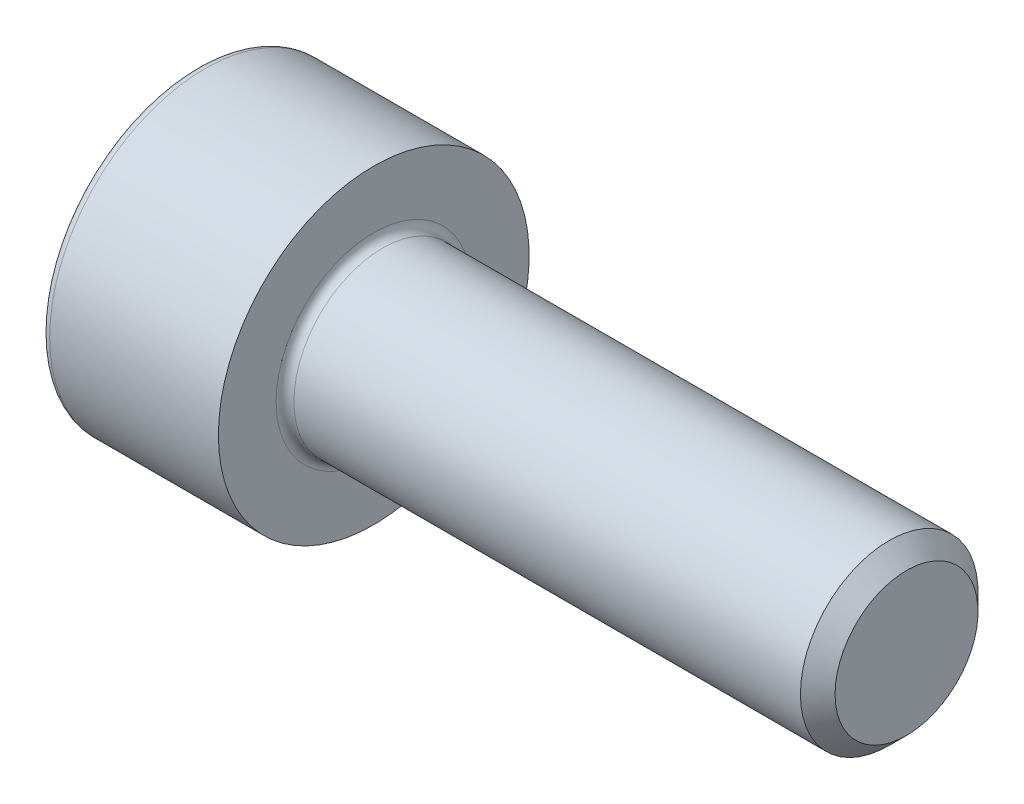
from build123d import *

# Parameters (mm, degrees)
FILLET1_R   = 0.2
FILLET2_R   = 0.2
HEX_2_DEPTH = 2


with BuildPart() as part:
    # BodySke → Base-Revolve (revolve)
    with BuildSketch(Plane.XY, mode=Mode.PRIVATE) as base_revolve_sk:
        Polygon((0, 0), (0, 3.5), (4, 3.5), (4, 2), (15.61, 2), (16, 1.61), (16, 0), align=None)
    revolve(base_revolve_sk.sketch.rotate(Axis((-31.75, 0, 0), (1, 0, 0)), 90), axis=Axis((-31.75, 0, 0), (1, 0, 0)))  # turned: the seam where the file's is

    # Fillet1
    fillet1_edges = [part.edges().sort_by_distance(p)[0] for p in [
        (4, 0, -2),
    ]]
    fillet(fillet1_edges, radius=FILLET1_R)

    # Fillet2
    fillet2_edges = [part.edges().sort_by_distance(p)[0] for p in [
        (0, 0, -3.5),
    ]]
    fillet(fillet2_edges, radius=FILLET2_R)

    # Sketch2 → Hex-PreBroach (revolve, cut)
    with BuildSketch(Plane.XY, mode=Mode.PRIVATE) as hex_prebroach_sk:
        Polygon((0, 1.5355), (2, 1.5355), (2.886521338, 0), (0, 0), align=None)
    revolve(hex_prebroach_sk.sketch.rotate(Axis((0, 0, 0), (1, 0, 0)), 90), axis=Axis((0, 0, 0), (1, 0, 0)), mode=Mode.SUBTRACT)  # turned: the seam where the file's is

    # Sketch3 → Hex 2 (cut)
    with BuildSketch(Plane(origin=(0, 0, 0), x_dir=(0, 0.5, 0.866025404), z_dir=(-1, 0, 0))):
        Polygon((0.886521338, 1.5355), (-0.886521338, 1.5355), (-1.773042677, 0), (-0.886521338, -1.5355), (0.886521338, -1.5355), (1.773042677, 0), align=None)
    extrude(amount=-HEX_2_DEPTH, mode=Mode.SUBTRACT)


solid = part.part
